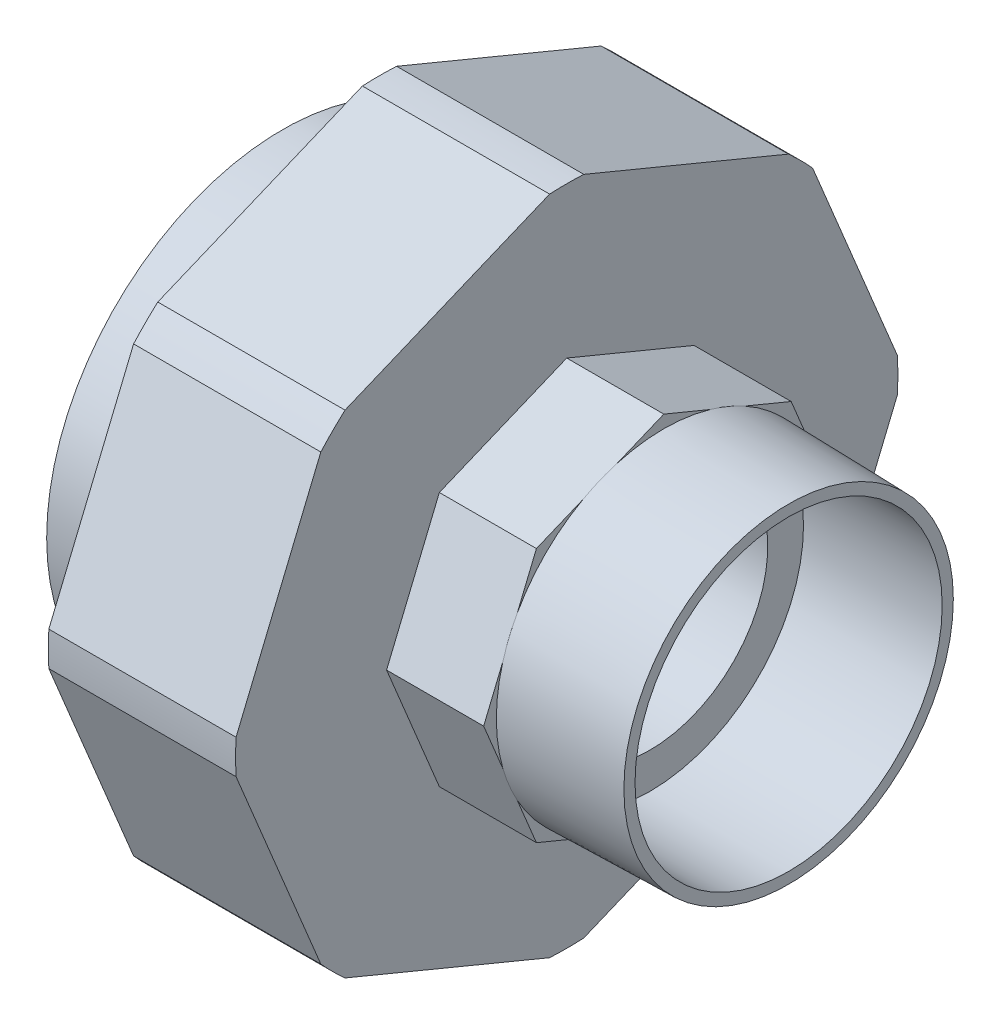
from build123d import *

# Parameters (mm, degrees)
CUT_EXTRUDE1_START = -27
SKETCH2_R          = 61.415464326
CUT_EXTRUDE1_DEPTH = 27
SKETCH3_R          = 40.122085913
CUT_EXTRUDE2_DEPTH = 14


with BuildPart() as part:
    # Sketch1 → Revolve1 (revolve)
    with BuildSketch(Plane.XY):
        Polygon((-32.314138911, -25), (-8.814138911, -25), (-8.814138911, -17), (20.685861089, -17), (20.685861089, -22.15), (40.685861089, -22.15), (40.685861089, -23.757238603), (22.685861089, -24.15), (22.685861089, -34.74048531), (8.685861089, -34.74048531), (8.685861089, -47.75), (-18.314138911, -47.75), (-18.314138911, -34), (-32.314138911, -34), align=None)
    revolve(axis=Axis((0, 0, 0), (1, 0, 0)))

    # Sketch2 → Cut-Extrude1 (cut)
    with BuildSketch(Plane(origin=(8.685861089, 0, 0), x_dir=(0, 0, -1), z_dir=(1, 0, 0)).offset(CUT_EXTRUDE1_START)):
        Circle(SKETCH2_R)
        Polygon((0, 48.707649013), (-34.441508913, 34.441508913), (-48.707649013, 0), (-34.441508913, -34.441508913), (0, -48.707649013), (34.441508913, -34.441508913), (48.707649013, 0), (34.441508913, 34.441508913), align=None, mode=Mode.SUBTRACT)
    extrude(amount=CUT_EXTRUDE1_DEPTH, mode=Mode.SUBTRACT)

    # Sketch3 → Cut-Extrude2 (cut)
    with BuildSketch(Plane(origin=(22.685861089, 0, 0), x_dir=(0, 0, -1), z_dir=(1, 0, 0))):
        Circle(SKETCH3_R)
        Polygon((0, 25.977412807), (-18.368804754, 18.368804754), (-25.977412807, 0), (-18.368804754, -18.368804754), (0, -25.977412807), (18.368804754, -18.368804754), (25.977412807, 0), (18.368804754, 18.368804754), align=None, mode=Mode.SUBTRACT)
    extrude(amount=-CUT_EXTRUDE2_DEPTH, mode=Mode.SUBTRACT)


solid = part.part
